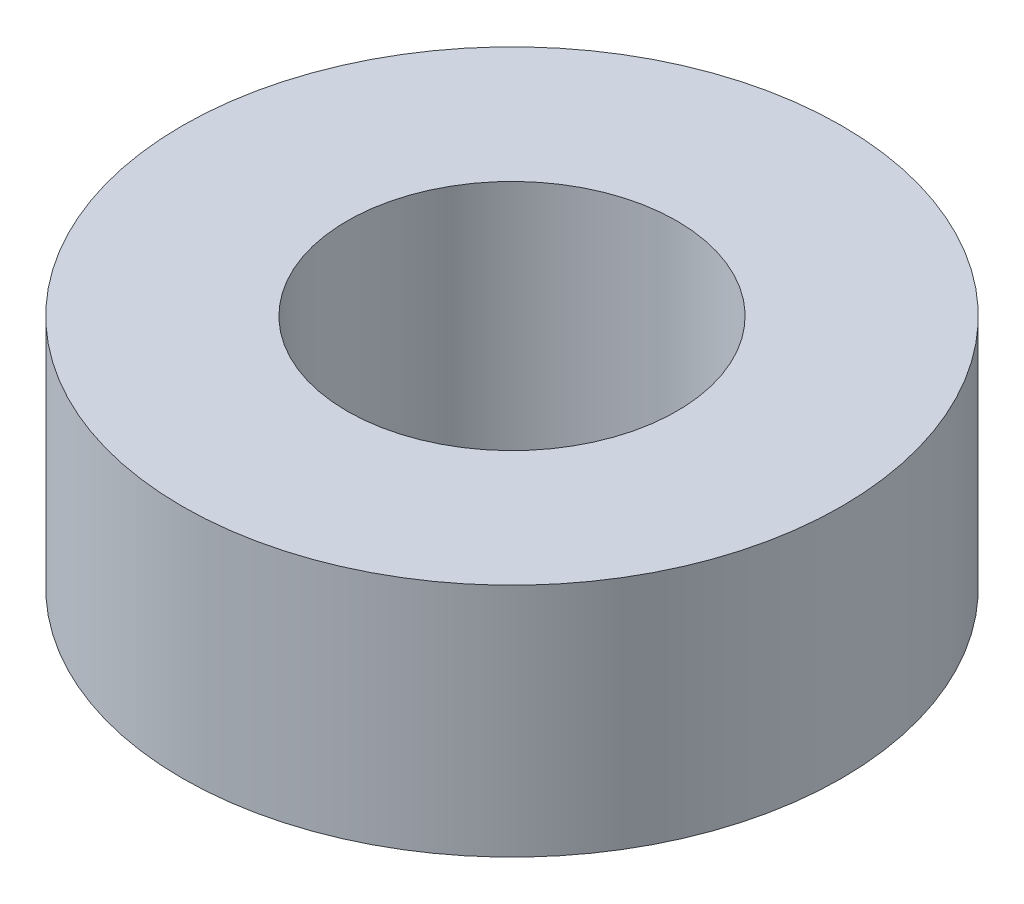
from build123d import *

# Parameters (mm, degrees)
SKETCH1_R           = 7
SKETCH1_R_2         = 3.5
BOSS_EXTRUDE1_DEPTH = 5


with BuildPart() as part:
    # Sketch1 → Boss-Extrude1 (new body)
    with BuildSketch(Plane(origin=(0, 0, 0), x_dir=(1, 0, 0), z_dir=(0, 1, 0))):
        Circle(SKETCH1_R)
        Circle(SKETCH1_R_2, mode=Mode.SUBTRACT)
    extrude(amount=BOSS_EXTRUDE1_DEPTH)


solid = part.part
